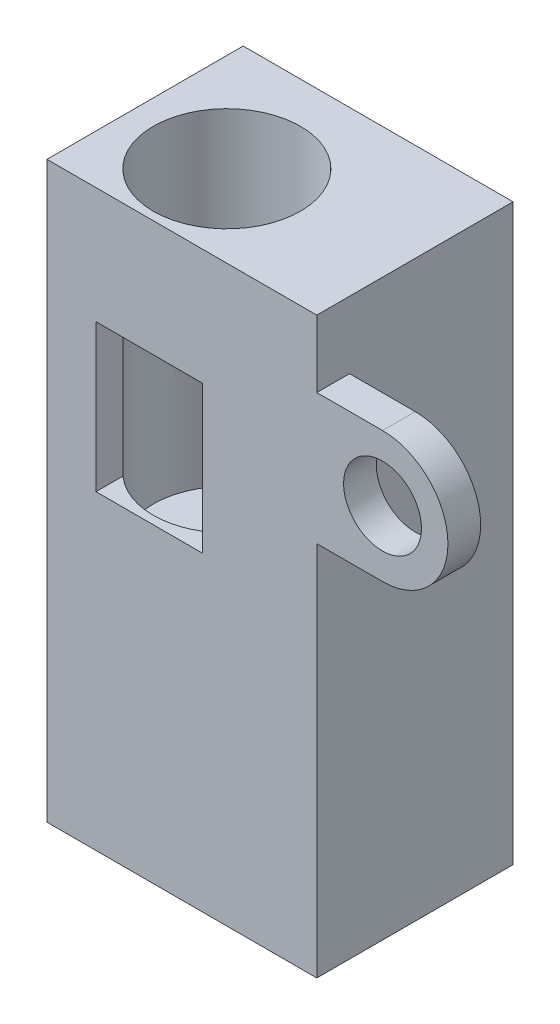
from build123d import *

# Parameters (mm, degrees)
BOSS_EXTRUDE4_DEPTH = 16.5
CUT_EXTRUDE2_DEPTH  = 1.5
CUT_EXTRUDE4_DEPTH  = 17.5
SKETCH6_W           = 12
SKETCH6_H           = 2
CUT_EXTRUDE5_DEPTH  = 17.5
BOSS_EXTRUDE5_DEPTH = 2
SKETCH10_R          = 2.38125
CUT_EXTRUDE6_DEPTH  = 13.606601718
CUT_EXTRUDE7_DEPTH  = 17.5
SKETCH12_R          = 2.38125
CUT_EXTRUDE8_DEPTH  = 6.35
SKETCH13_R          = 4.5
CUT_EXTRUDE13_DEPTH = 20
SKETCH14_W          = 6.5
SKETCH14_H          = 9
CUT_EXTRUDE14_DEPTH = 6


with BuildPart() as part:
    # Sketch1 → Boss-Extrude4 (new body)
    with BuildSketch(Plane(origin=(0, 0, 0), x_dir=(0, 0, -1), z_dir=(1, 0, 0))):
        Polygon((0, 0), (0, 37.1), (-10.606601718, 47.706601718), (12, 47.706601718), (12, 0), align=None)
    extrude(amount=BOSS_EXTRUDE4_DEPTH)

    # Sketch4 → Cut-Extrude2 (cut)
    with BuildSketch(Plane.ZY):
        Polygon((0, 37.1), (0, 47.706601718), (10.606601718, 47.706601718), align=None)
    extrude(amount=-CUT_EXTRUDE2_DEPTH, mode=Mode.SUBTRACT)

    # Sketch5 → Cut-Extrude4 (cut, through all)
    with BuildSketch(Plane(origin=(16.5, 0, 0), x_dir=(0, 0, -1), z_dir=(1, 0, 0))):
        Polygon((-3.566952421, 40.666952421), (-2.859845639, 39.959845639), (-1.799185468, 41.020505811), (0, 39.221320344), (0, 42.756854249), (-2.683068944, 45.439923194), (-4.450835897, 43.672156241), (-3.036622335, 42.257942678), (-4.097282506, 41.197282506), align=None)
    extrude(amount=-CUT_EXTRUDE4_DEPTH, mode=Mode.SUBTRACT)

    # Sketch6 → Cut-Extrude5 (cut, through all)
    with BuildSketch(Plane(origin=(16.5, 0, 0), x_dir=(0, 0, -1), z_dir=(1, 0, 0))):
        with Locations((6, 1)):
            Rectangle(SKETCH6_W, SKETCH6_H)
    extrude(amount=-CUT_EXTRUDE5_DEPTH, mode=Mode.SUBTRACT)

    # Sketch9 → Boss-Extrude5 (add)
    with BuildSketch(Plane.XY):
        with BuildLine():
            Line((16.5, 29), (16.5, 25))
            Line((16.5, 25), (20.518219338, 25))
            ThreePointArc((20.518219338, 25), (24.518219338, 29), (20.518219338, 33))
            Line((20.518219338, 33), (16.5, 33))
            Line((16.5, 33), (16.5, 29))
        make_face()
    extrude(amount=-BOSS_EXTRUDE5_DEPTH)

    # Sketch10 → Cut-Extrude6 (cut, through all)
    with BuildSketch(Plane(origin=(0, 0, -2), x_dir=(-1, 0, 0), z_dir=(0, 0, -1))):
        with Locations((-20.518219338, 29)):
            Circle(SKETCH10_R)
    extrude(amount=-CUT_EXTRUDE6_DEPTH, mode=Mode.SUBTRACT)

    # Sketch11 → Cut-Extrude7 (cut, through all)
    with BuildSketch(Plane(origin=(16.5, 0, 0), x_dir=(0, 0, -1), z_dir=(1, 0, 0))):
        Polygon((0, 37.1), (-10.606601718, 47.706601718), (12, 47.706601718), (12, 37.1), align=None)
    extrude(amount=-CUT_EXTRUDE7_DEPTH, mode=Mode.SUBTRACT)

    # Sketch12 → Cut-Extrude8 (cut)
    with BuildSketch(Plane.XZ.offset(-2)):
        with Locations((8.25, -6)):
            Circle(SKETCH12_R)
    extrude(amount=-CUT_EXTRUDE8_DEPTH, mode=Mode.SUBTRACT)

    # Sketch13 → Cut-Extrude13 (cut)
    with BuildSketch(Plane(origin=(0, 37.1, 0), x_dir=(1, 0, 0), z_dir=(0, 1, 0))):
        with Locations((6, 5)):
            Circle(SKETCH13_R)
    extrude(amount=-CUT_EXTRUDE13_DEPTH, mode=Mode.SUBTRACT)

    # Sketch14 → Cut-Extrude14 (cut)
    with BuildSketch(Plane.XY):
        with Locations((6.25, 25.5)):
            Rectangle(SKETCH14_W, SKETCH14_H)
    extrude(amount=-CUT_EXTRUDE14_DEPTH, mode=Mode.SUBTRACT)


solid = part.part
